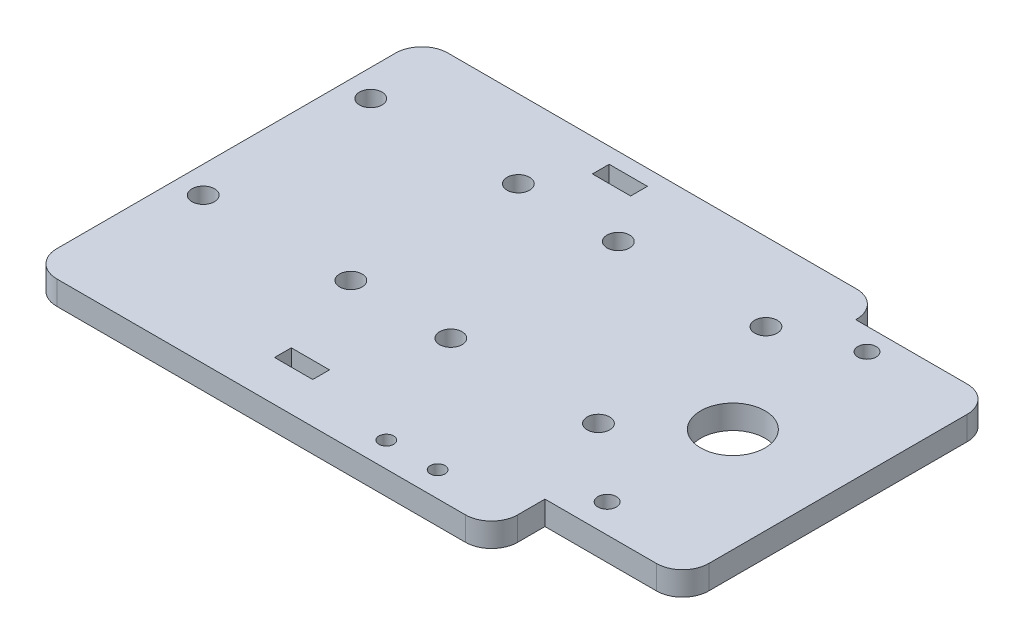
from build123d import *

# Parameters (mm, degrees)
SKETCH1_R           = 2.15
SKETCH1_R_2         = 6.15
SKETCH1_R_3         = 1.75
SKETCH1_R_4         = 1.4
SKETCH1_W           = 7.3
SKETCH1_H           = 3.2
BOSS_EXTRUDE1_DEPTH = 4.55


with BuildPart() as part:
    # Sketch1 → Boss-Extrude1 (new body)
    with BuildSketch(Plane(origin=(0, 0, 0), x_dir=(1, 0, 0), z_dir=(0, 1, 0))):
        with BuildLine():
            Line((5, 0), (83.06, 0))
            ThreePointArc((83.06, 0), (86.595533906, 1.464466094), (88.06, 5))
            Line((88.06, 5), (88.06, 10.2))
            Line((88.06, 10.2), (109.36, 10.2))
            ThreePointArc((109.36, 10.2), (112.895533906, 11.664466094), (114.36, 15.2))
            Line((114.36, 15.2), (114.36, 64.57))
            ThreePointArc((114.36, 64.57), (112.895533906, 68.105533906), (109.36, 69.57))
            Line((109.36, 69.57), (88.06, 69.57))
            Line((88.06, 69.57), (88.06, 69.73))
            ThreePointArc((88.06, 69.73), (86.595533906, 73.265533906), (83.06, 74.73))
            Line((83.06, 74.73), (5, 74.73))
            ThreePointArc((5, 74.73), (1.464466094, 73.265533906), (0, 69.73))
            Line((0, 69.73), (0, 5))
            ThreePointArc((0, 5), (1.464466094, 1.464466094), (5, 0))
        make_face()
        with Locations((5.15, 59.83)):
            Circle(SKETCH1_R, mode=Mode.SUBTRACT)
        with Locations((33.35, 59.83)):
            Circle(SKETCH1_R, mode=Mode.SUBTRACT)
        with Locations((52.45, 59.83)):
            Circle(SKETCH1_R, mode=Mode.SUBTRACT)
        with Locations((80.65, 59.83)):
            Circle(SKETCH1_R, mode=Mode.SUBTRACT)
        with Locations((5.15, 27.83)):
            Circle(SKETCH1_R, mode=Mode.SUBTRACT)
        with Locations((33.35, 27.83)):
            Circle(SKETCH1_R, mode=Mode.SUBTRACT)
        with Locations((52.45, 27.83)):
            Circle(SKETCH1_R, mode=Mode.SUBTRACT)
        with Locations((80.65, 27.83)):
            Circle(SKETCH1_R, mode=Mode.SUBTRACT)
        with Locations((94.47, 39.69)):
            Circle(SKETCH1_R_2, mode=Mode.SUBTRACT)
        with Locations((94.45, 65.33)):
            Circle(SKETCH1_R_3, mode=Mode.SUBTRACT)
        with Locations((94.45, 15.69)):
            Circle(SKETCH1_R_3, mode=Mode.SUBTRACT)
        with Locations((63.15, 4.8)):
            Circle(SKETCH1_R_4, mode=Mode.SUBTRACT)
        with Locations((72.95, 4.8)):
            Circle(SKETCH1_R_4, mode=Mode.SUBTRACT)
        with Locations((42.45, 70.13)):
            Rectangle(SKETCH1_W, SKETCH1_H, mode=Mode.SUBTRACT)
        with Locations((42.45, 9.4)):
            Rectangle(SKETCH1_W, SKETCH1_H, mode=Mode.SUBTRACT)
    extrude(amount=BOSS_EXTRUDE1_DEPTH)


solid = part.part
